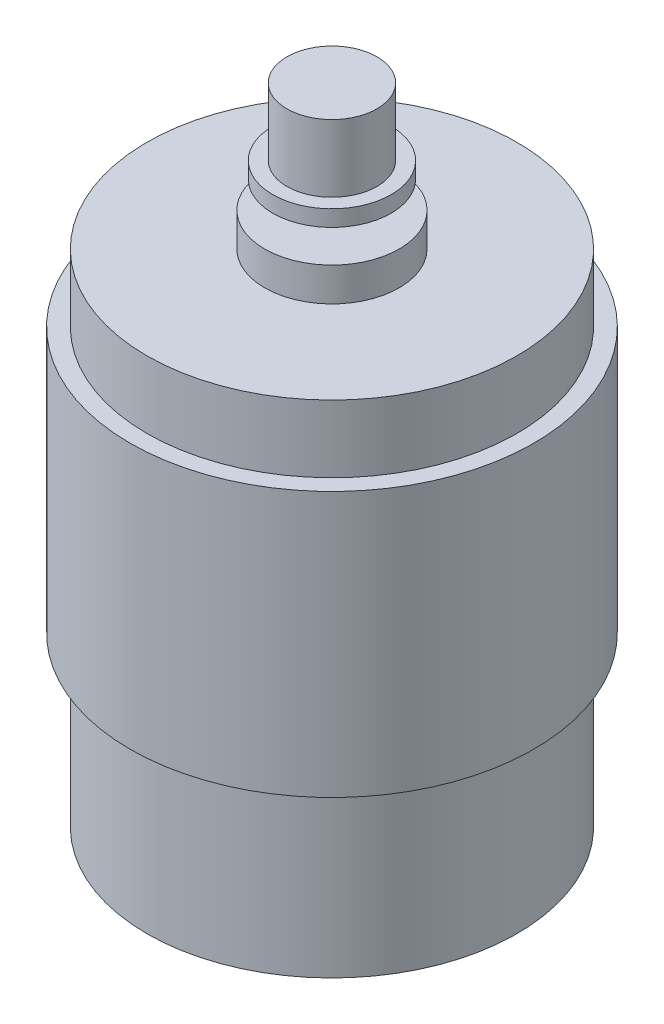
from build123d import *

# Parameters (mm, degrees)
CROQUIS1_R              = 13.75
SALIENTE_EXTRUIR1_DEPTH = 12.5
CROQUIS2_R              = 15
SALIENTE_EXTRUIR2_DEPTH = 19.7
CROQUIS3_R              = 13.75
SALIENTE_EXTRUIR3_DEPTH = 5
CROQUIS4_R              = 5
SALIENTE_EXTRUIR4_DEPTH = 2.5
CROQUIS5_R              = 1.15
SALIENTE_EXTRUIR5_DEPTH = 2
CROQUIS6_R              = 4.4
SALIENTE_EXTRUIR6_DEPTH = 1.2
CROQUIS7_R              = 3.35
SALIENTE_EXTRUIR7_DEPTH = 5


with BuildPart() as part:
    # Croquis1 → Saliente-Extruir1 (new body)
    with BuildSketch(Plane(origin=(0, 0, 0), x_dir=(1, 0, 0), z_dir=(0, 1, 0))):
        Circle(CROQUIS1_R)
    extrude(amount=SALIENTE_EXTRUIR1_DEPTH)

    # Croquis2 → Saliente-Extruir2 (add)
    with BuildSketch(Plane(origin=(0, 12.5, 0), x_dir=(1, 0, 0), z_dir=(0, 1, 0))):
        Circle(CROQUIS2_R)
    extrude(amount=SALIENTE_EXTRUIR2_DEPTH)

    # Croquis3 → Saliente-Extruir3 (add)
    with BuildSketch(Plane(origin=(0, 32.2, 0), x_dir=(1, 0, 0), z_dir=(0, 1, 0))):
        Circle(CROQUIS3_R)
    extrude(amount=SALIENTE_EXTRUIR3_DEPTH)

    # Croquis4 → Saliente-Extruir4 (add)
    with BuildSketch(Plane(origin=(0, 37.2, 0), x_dir=(1, 0, 0), z_dir=(0, 1, 0))):
        Circle(CROQUIS4_R)
    extrude(amount=SALIENTE_EXTRUIR4_DEPTH)

    # Croquis5 → Saliente-Extruir5 (add)
    with BuildSketch(Plane(origin=(0, 39.7, 0), x_dir=(1, 0, 0), z_dir=(0, 1, 0))):
        Circle(CROQUIS5_R)
    extrude(amount=SALIENTE_EXTRUIR5_DEPTH)

    # Croquis6 → Saliente-Extruir6 (add)
    with BuildSketch(Plane(origin=(0, 41.7, 0), x_dir=(1, 0, 0), z_dir=(0, 1, 0))):
        Circle(CROQUIS6_R)
    extrude(amount=SALIENTE_EXTRUIR6_DEPTH)

    # Croquis7 → Saliente-Extruir7 (add)
    with BuildSketch(Plane(origin=(0, 42.9, 0), x_dir=(1, 0, 0), z_dir=(0, 1, 0))):
        Circle(CROQUIS7_R)
    extrude(amount=SALIENTE_EXTRUIR7_DEPTH)


solid = part.part
